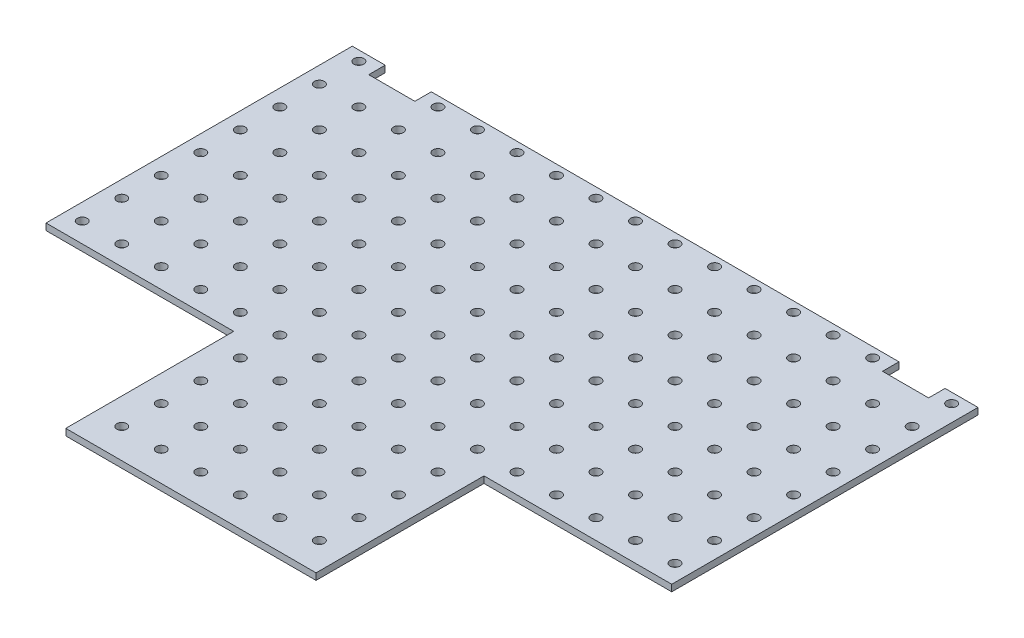
from build123d import *

# Parameters (mm, degrees)
SKETCH1_R           = 1.5
BOSS_EXTRUDE1_DEPTH = 2
SKETCH2_W           = 14
SKETCH2_H           = 5
CUT_EXTRUDE1_DEPTH  = 10


with BuildPart() as part:
    # Sketch1 → Boss-Extrude1 (new body)
    with BuildSketch(Plane(origin=(0, 0, 0), x_dir=(1, 0, 0), z_dir=(0, 1, 0))):
        Polygon((-100, -24), (-43, -24), (-43, -75), (33, -75), (33, -24), (90, -24), (90, 69), (-100, 69), align=None)
        with Locations((-95, 66)):
            Circle(SKETCH1_R, mode=Mode.SUBTRACT)
        with Locations((-83, 66)):
            Circle(SKETCH1_R, mode=Mode.SUBTRACT)
        with Locations((-71, 66)):
            Circle(SKETCH1_R, mode=Mode.SUBTRACT)
        with Locations((-59, 66)):
            Circle(SKETCH1_R, mode=Mode.SUBTRACT)
        with Locations((-47, 66)):
            Circle(SKETCH1_R, mode=Mode.SUBTRACT)
        with Locations((-35, 66)):
            Circle(SKETCH1_R, mode=Mode.SUBTRACT)
        with Locations((-23, 66)):
            Circle(SKETCH1_R, mode=Mode.SUBTRACT)
        with Locations((-11, 66)):
            Circle(SKETCH1_R, mode=Mode.SUBTRACT)
        with Locations((1, 66)):
            Circle(SKETCH1_R, mode=Mode.SUBTRACT)
        with Locations((13, 66)):
            Circle(SKETCH1_R, mode=Mode.SUBTRACT)
        with Locations((25, 66)):
            Circle(SKETCH1_R, mode=Mode.SUBTRACT)
        with Locations((37, 66)):
            Circle(SKETCH1_R, mode=Mode.SUBTRACT)
        with Locations((49, 66)):
            Circle(SKETCH1_R, mode=Mode.SUBTRACT)
        with Locations((61, 66)):
            Circle(SKETCH1_R, mode=Mode.SUBTRACT)
        with Locations((73, 66)):
            Circle(SKETCH1_R, mode=Mode.SUBTRACT)
        with Locations((85, 66)):
            Circle(SKETCH1_R, mode=Mode.SUBTRACT)
        with Locations((-83, 54)):
            Circle(SKETCH1_R, mode=Mode.SUBTRACT)
        with Locations((-71, 54)):
            Circle(SKETCH1_R, mode=Mode.SUBTRACT)
        with Locations((-59, 54)):
            Circle(SKETCH1_R, mode=Mode.SUBTRACT)
        with Locations((-47, 54)):
            Circle(SKETCH1_R, mode=Mode.SUBTRACT)
        with Locations((-35, 54)):
            Circle(SKETCH1_R, mode=Mode.SUBTRACT)
        with Locations((-23, 54)):
            Circle(SKETCH1_R, mode=Mode.SUBTRACT)
        with Locations((-11, 54)):
            Circle(SKETCH1_R, mode=Mode.SUBTRACT)
        with Locations((1, 54)):
            Circle(SKETCH1_R, mode=Mode.SUBTRACT)
        with Locations((13, 54)):
            Circle(SKETCH1_R, mode=Mode.SUBTRACT)
        with Locations((25, 54)):
            Circle(SKETCH1_R, mode=Mode.SUBTRACT)
        with Locations((37, 54)):
            Circle(SKETCH1_R, mode=Mode.SUBTRACT)
        with Locations((49, 54)):
            Circle(SKETCH1_R, mode=Mode.SUBTRACT)
        with Locations((61, 54)):
            Circle(SKETCH1_R, mode=Mode.SUBTRACT)
        with Locations((73, 54)):
            Circle(SKETCH1_R, mode=Mode.SUBTRACT)
        with Locations((85, 54)):
            Circle(SKETCH1_R, mode=Mode.SUBTRACT)
        with Locations((-83, 42)):
            Circle(SKETCH1_R, mode=Mode.SUBTRACT)
        with Locations((-71, 42)):
            Circle(SKETCH1_R, mode=Mode.SUBTRACT)
        with Locations((-59, 42)):
            Circle(SKETCH1_R, mode=Mode.SUBTRACT)
        with Locations((-47, 42)):
            Circle(SKETCH1_R, mode=Mode.SUBTRACT)
        with Locations((-35, 42)):
            Circle(SKETCH1_R, mode=Mode.SUBTRACT)
        with Locations((-23, 42)):
            Circle(SKETCH1_R, mode=Mode.SUBTRACT)
        with Locations((-11, 42)):
            Circle(SKETCH1_R, mode=Mode.SUBTRACT)
        with Locations((1, 42)):
            Circle(SKETCH1_R, mode=Mode.SUBTRACT)
        with Locations((13, 42)):
            Circle(SKETCH1_R, mode=Mode.SUBTRACT)
        with Locations((25, 42)):
            Circle(SKETCH1_R, mode=Mode.SUBTRACT)
        with Locations((37, 42)):
            Circle(SKETCH1_R, mode=Mode.SUBTRACT)
        with Locations((49, 42)):
            Circle(SKETCH1_R, mode=Mode.SUBTRACT)
        with Locations((61, 42)):
            Circle(SKETCH1_R, mode=Mode.SUBTRACT)
        with Locations((73, 42)):
            Circle(SKETCH1_R, mode=Mode.SUBTRACT)
        with Locations((85, 42)):
            Circle(SKETCH1_R, mode=Mode.SUBTRACT)
        with Locations((-83, 30)):
            Circle(SKETCH1_R, mode=Mode.SUBTRACT)
        with Locations((-71, 30)):
            Circle(SKETCH1_R, mode=Mode.SUBTRACT)
        with Locations((-59, 30)):
            Circle(SKETCH1_R, mode=Mode.SUBTRACT)
        with Locations((-47, 30)):
            Circle(SKETCH1_R, mode=Mode.SUBTRACT)
        with Locations((-35, 30)):
            Circle(SKETCH1_R, mode=Mode.SUBTRACT)
        with Locations((-23, 30)):
            Circle(SKETCH1_R, mode=Mode.SUBTRACT)
        with Locations((-11, 30)):
            Circle(SKETCH1_R, mode=Mode.SUBTRACT)
        with Locations((1, 30)):
            Circle(SKETCH1_R, mode=Mode.SUBTRACT)
        with Locations((13, 30)):
            Circle(SKETCH1_R, mode=Mode.SUBTRACT)
        with Locations((25, 30)):
            Circle(SKETCH1_R, mode=Mode.SUBTRACT)
        with Locations((37, 30)):
            Circle(SKETCH1_R, mode=Mode.SUBTRACT)
        with Locations((49, 30)):
            Circle(SKETCH1_R, mode=Mode.SUBTRACT)
        with Locations((61, 30)):
            Circle(SKETCH1_R, mode=Mode.SUBTRACT)
        with Locations((73, 30)):
            Circle(SKETCH1_R, mode=Mode.SUBTRACT)
        with Locations((85, 30)):
            Circle(SKETCH1_R, mode=Mode.SUBTRACT)
        with Locations((-83, 18)):
            Circle(SKETCH1_R, mode=Mode.SUBTRACT)
        with Locations((-71, 18)):
            Circle(SKETCH1_R, mode=Mode.SUBTRACT)
        with Locations((-59, 18)):
            Circle(SKETCH1_R, mode=Mode.SUBTRACT)
        with Locations((-47, 18)):
            Circle(SKETCH1_R, mode=Mode.SUBTRACT)
        with Locations((-35, 18)):
            Circle(SKETCH1_R, mode=Mode.SUBTRACT)
        with Locations((-23, 18)):
            Circle(SKETCH1_R, mode=Mode.SUBTRACT)
        with Locations((-11, 18)):
            Circle(SKETCH1_R, mode=Mode.SUBTRACT)
        with Locations((1, 18)):
            Circle(SKETCH1_R, mode=Mode.SUBTRACT)
        with Locations((13, 18)):
            Circle(SKETCH1_R, mode=Mode.SUBTRACT)
        with Locations((25, 18)):
            Circle(SKETCH1_R, mode=Mode.SUBTRACT)
        with Locations((37, 18)):
            Circle(SKETCH1_R, mode=Mode.SUBTRACT)
        with Locations((49, 18)):
            Circle(SKETCH1_R, mode=Mode.SUBTRACT)
        with Locations((61, 18)):
            Circle(SKETCH1_R, mode=Mode.SUBTRACT)
        with Locations((73, 18)):
            Circle(SKETCH1_R, mode=Mode.SUBTRACT)
        with Locations((85, 18)):
            Circle(SKETCH1_R, mode=Mode.SUBTRACT)
        with Locations((-83, 6)):
            Circle(SKETCH1_R, mode=Mode.SUBTRACT)
        with Locations((-71, 6)):
            Circle(SKETCH1_R, mode=Mode.SUBTRACT)
        with Locations((-59, 6)):
            Circle(SKETCH1_R, mode=Mode.SUBTRACT)
        with Locations((-47, 6)):
            Circle(SKETCH1_R, mode=Mode.SUBTRACT)
        with Locations((-35, 6)):
            Circle(SKETCH1_R, mode=Mode.SUBTRACT)
        with Locations((-23, 6)):
            Circle(SKETCH1_R, mode=Mode.SUBTRACT)
        with Locations((-11, 6)):
            Circle(SKETCH1_R, mode=Mode.SUBTRACT)
        with Locations((1, 6)):
            Circle(SKETCH1_R, mode=Mode.SUBTRACT)
        with Locations((13, 6)):
            Circle(SKETCH1_R, mode=Mode.SUBTRACT)
        with Locations((25, 6)):
            Circle(SKETCH1_R, mode=Mode.SUBTRACT)
        with Locations((37, 6)):
            Circle(SKETCH1_R, mode=Mode.SUBTRACT)
        with Locations((49, 6)):
            Circle(SKETCH1_R, mode=Mode.SUBTRACT)
        with Locations((61, 6)):
            Circle(SKETCH1_R, mode=Mode.SUBTRACT)
        with Locations((73, 6)):
            Circle(SKETCH1_R, mode=Mode.SUBTRACT)
        with Locations((85, 6)):
            Circle(SKETCH1_R, mode=Mode.SUBTRACT)
        with Locations((-83, -6)):
            Circle(SKETCH1_R, mode=Mode.SUBTRACT)
        with Locations((-71, -6)):
            Circle(SKETCH1_R, mode=Mode.SUBTRACT)
        with Locations((-59, -6)):
            Circle(SKETCH1_R, mode=Mode.SUBTRACT)
        with Locations((-47, -6)):
            Circle(SKETCH1_R, mode=Mode.SUBTRACT)
        with Locations((-35, -6)):
            Circle(SKETCH1_R, mode=Mode.SUBTRACT)
        with Locations((-23, -6)):
            Circle(SKETCH1_R, mode=Mode.SUBTRACT)
        with Locations((-11, -6)):
            Circle(SKETCH1_R, mode=Mode.SUBTRACT)
        with Locations((1, -6)):
            Circle(SKETCH1_R, mode=Mode.SUBTRACT)
        with Locations((13, -6)):
            Circle(SKETCH1_R, mode=Mode.SUBTRACT)
        with Locations((25, -6)):
            Circle(SKETCH1_R, mode=Mode.SUBTRACT)
        with Locations((37, -6)):
            Circle(SKETCH1_R, mode=Mode.SUBTRACT)
        with Locations((49, -6)):
            Circle(SKETCH1_R, mode=Mode.SUBTRACT)
        with Locations((61, -6)):
            Circle(SKETCH1_R, mode=Mode.SUBTRACT)
        with Locations((73, -6)):
            Circle(SKETCH1_R, mode=Mode.SUBTRACT)
        with Locations((85, -6)):
            Circle(SKETCH1_R, mode=Mode.SUBTRACT)
        with Locations((-83, -18)):
            Circle(SKETCH1_R, mode=Mode.SUBTRACT)
        with Locations((-71, -18)):
            Circle(SKETCH1_R, mode=Mode.SUBTRACT)
        with Locations((-59, -18)):
            Circle(SKETCH1_R, mode=Mode.SUBTRACT)
        with Locations((-47, -18)):
            Circle(SKETCH1_R, mode=Mode.SUBTRACT)
        with Locations((-35, -18)):
            Circle(SKETCH1_R, mode=Mode.SUBTRACT)
        with Locations((-23, -18)):
            Circle(SKETCH1_R, mode=Mode.SUBTRACT)
        with Locations((-11, -18)):
            Circle(SKETCH1_R, mode=Mode.SUBTRACT)
        with Locations((1, -18)):
            Circle(SKETCH1_R, mode=Mode.SUBTRACT)
        with Locations((13, -18)):
            Circle(SKETCH1_R, mode=Mode.SUBTRACT)
        with Locations((25, -18)):
            Circle(SKETCH1_R, mode=Mode.SUBTRACT)
        with Locations((37, -18)):
            Circle(SKETCH1_R, mode=Mode.SUBTRACT)
        with Locations((49, -18)):
            Circle(SKETCH1_R, mode=Mode.SUBTRACT)
        with Locations((61, -18)):
            Circle(SKETCH1_R, mode=Mode.SUBTRACT)
        with Locations((73, -18)):
            Circle(SKETCH1_R, mode=Mode.SUBTRACT)
        with Locations((85, -18)):
            Circle(SKETCH1_R, mode=Mode.SUBTRACT)
        with Locations((-35, -30)):
            Circle(SKETCH1_R, mode=Mode.SUBTRACT)
        with Locations((-23, -30)):
            Circle(SKETCH1_R, mode=Mode.SUBTRACT)
        with Locations((-11, -30)):
            Circle(SKETCH1_R, mode=Mode.SUBTRACT)
        with Locations((1, -30)):
            Circle(SKETCH1_R, mode=Mode.SUBTRACT)
        with Locations((13, -30)):
            Circle(SKETCH1_R, mode=Mode.SUBTRACT)
        with Locations((25, -30)):
            Circle(SKETCH1_R, mode=Mode.SUBTRACT)
        with Locations((-35, -42)):
            Circle(SKETCH1_R, mode=Mode.SUBTRACT)
        with Locations((-23, -42)):
            Circle(SKETCH1_R, mode=Mode.SUBTRACT)
        with Locations((-11, -42)):
            Circle(SKETCH1_R, mode=Mode.SUBTRACT)
        with Locations((1, -42)):
            Circle(SKETCH1_R, mode=Mode.SUBTRACT)
        with Locations((13, -42)):
            Circle(SKETCH1_R, mode=Mode.SUBTRACT)
        with Locations((25, -42)):
            Circle(SKETCH1_R, mode=Mode.SUBTRACT)
        with Locations((-35, -54)):
            Circle(SKETCH1_R, mode=Mode.SUBTRACT)
        with Locations((-23, -54)):
            Circle(SKETCH1_R, mode=Mode.SUBTRACT)
        with Locations((-11, -54)):
            Circle(SKETCH1_R, mode=Mode.SUBTRACT)
        with Locations((1, -54)):
            Circle(SKETCH1_R, mode=Mode.SUBTRACT)
        with Locations((13, -54)):
            Circle(SKETCH1_R, mode=Mode.SUBTRACT)
        with Locations((25, -54)):
            Circle(SKETCH1_R, mode=Mode.SUBTRACT)
        with Locations((-35, -66)):
            Circle(SKETCH1_R, mode=Mode.SUBTRACT)
        with Locations((-23, -66)):
            Circle(SKETCH1_R, mode=Mode.SUBTRACT)
        with Locations((-11, -66)):
            Circle(SKETCH1_R, mode=Mode.SUBTRACT)
        with Locations((1, -66)):
            Circle(SKETCH1_R, mode=Mode.SUBTRACT)
        with Locations((13, -66)):
            Circle(SKETCH1_R, mode=Mode.SUBTRACT)
        with Locations((25, -66)):
            Circle(SKETCH1_R, mode=Mode.SUBTRACT)
        with Locations((-95, 54)):
            Circle(SKETCH1_R, mode=Mode.SUBTRACT)
        with Locations((-95, 42)):
            Circle(SKETCH1_R, mode=Mode.SUBTRACT)
        with Locations((-95, 30)):
            Circle(SKETCH1_R, mode=Mode.SUBTRACT)
        with Locations((-95, 18)):
            Circle(SKETCH1_R, mode=Mode.SUBTRACT)
        with Locations((-95, 6)):
            Circle(SKETCH1_R, mode=Mode.SUBTRACT)
        with Locations((-95, -6)):
            Circle(SKETCH1_R, mode=Mode.SUBTRACT)
        with Locations((-95, -18)):
            Circle(SKETCH1_R, mode=Mode.SUBTRACT)
    extrude(amount=BOSS_EXTRUDE1_DEPTH)

    # Sketch2 → Cut-Extrude1 (cut)
    with BuildSketch(Plane(origin=(0, 2, 0), x_dir=(1, 0, 0), z_dir=(0, 1, 0))):
        with Locations((-83, 66.5)):
            Rectangle(SKETCH2_W, SKETCH2_H)
        with Locations((73, 66.5)):
            Rectangle(SKETCH2_W, SKETCH2_H)
    extrude(amount=-CUT_EXTRUDE1_DEPTH, mode=Mode.SUBTRACT)


solid = part.part
